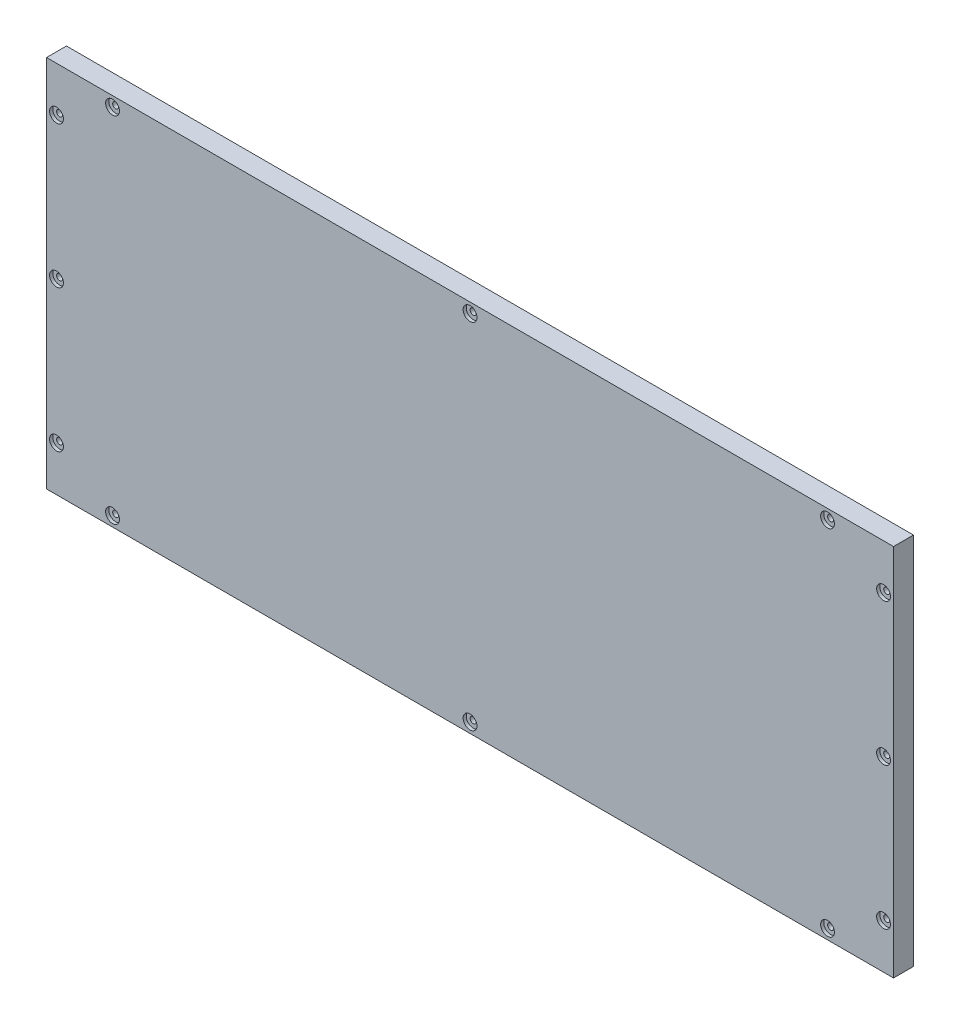
from build123d import *

# Parameters (mm, degrees)
SKETCH1_W                                           = 340
SKETCH1_H                                           = 150
BOSS_EXTRUDE1_DEPTH                                 = 8
CBORE_FOR_2_BINDING_HEAD_MACHINE_SCREW1_D           = 2.4384
CBORE_FOR_2_BINDING_HEAD_MACHINE_SCREW1_DEPTH       = 20
CBORE_FOR_2_BINDING_HEAD_MACHINE_SCREW1_CBORE_D     = 5.55752
CBORE_FOR_2_BINDING_HEAD_MACHINE_SCREW1_CBORE_DEPTH = 1.27
CBORE_FOR_2_BINDING_HEAD_MACHINE_SCREW1_TIP         = 0.732569267


with BuildPart() as part:
    # Sketch1 → Boss-Extrude1 (new body)
    with BuildSketch(Plane.XY):
        with Locations((170, 75)):
            Rectangle(SKETCH1_W, SKETCH1_H)
    extrude(amount=BOSS_EXTRUDE1_DEPTH)

    # CBORE for #2 Binding Head Machine Screw1
    with Locations(Plane.XY.offset(8)):
        with Locations((4, 132), (4, 75), (4, 18), (26.5, 4), (170, 4), (313.5, 4), (336, 18), (336, 75), (336, 132), (313.5, 146), (170, 146), (26.5, 146)):
            CounterBoreHole(CBORE_FOR_2_BINDING_HEAD_MACHINE_SCREW1_D / 2, CBORE_FOR_2_BINDING_HEAD_MACHINE_SCREW1_CBORE_D / 2, CBORE_FOR_2_BINDING_HEAD_MACHINE_SCREW1_CBORE_DEPTH, depth=CBORE_FOR_2_BINDING_HEAD_MACHINE_SCREW1_DEPTH)
            with Locations((0, 0, -(CBORE_FOR_2_BINDING_HEAD_MACHINE_SCREW1_DEPTH + CBORE_FOR_2_BINDING_HEAD_MACHINE_SCREW1_TIP / 2))):  # 118° drill point
                Cone(0, CBORE_FOR_2_BINDING_HEAD_MACHINE_SCREW1_D / 2, CBORE_FOR_2_BINDING_HEAD_MACHINE_SCREW1_TIP, mode=Mode.SUBTRACT)


solid = part.part
